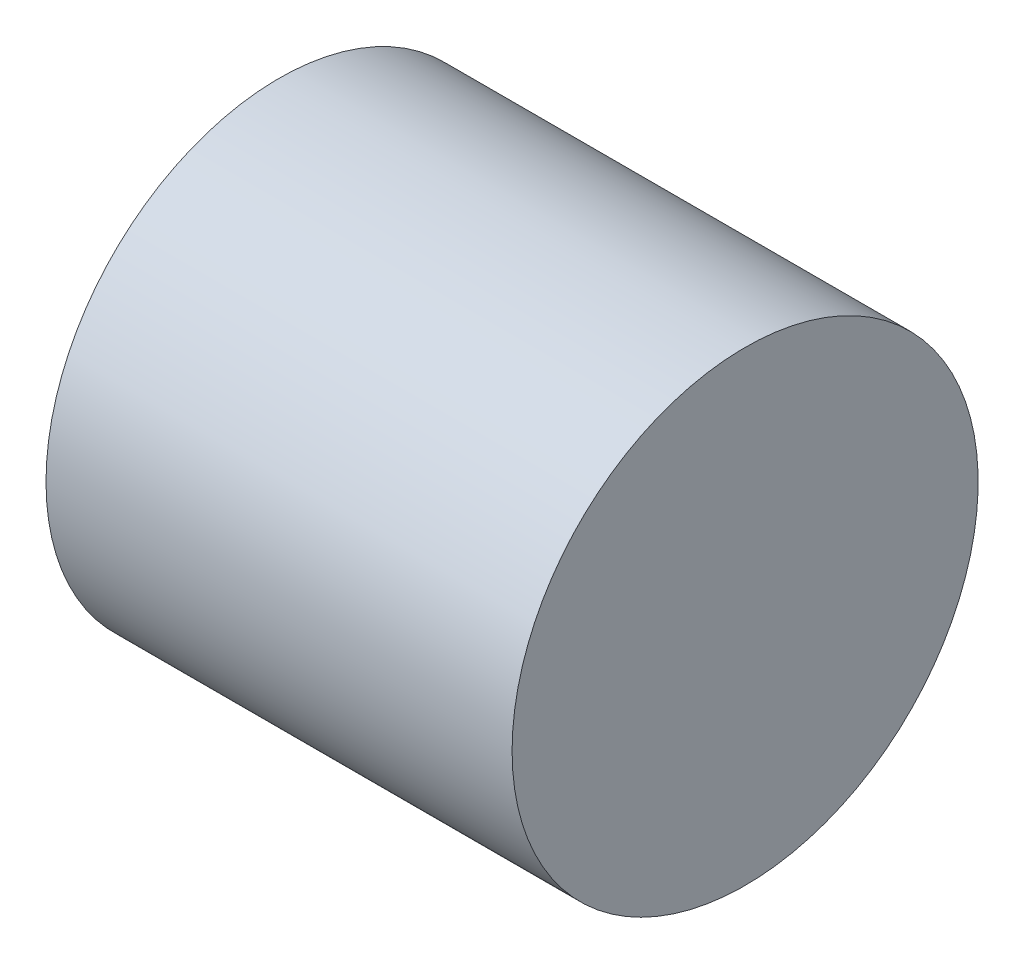
from build123d import *

# Parameters (mm, degrees)
SCHIZZO1_W = 40
SCHIZZO1_H = 20


with BuildPart() as part:
    # Schizzo1 → Rivoluzione1 (revolve)
    with BuildSketch(Plane.XY):
        with Locations((20, 10)):
            Rectangle(SCHIZZO1_W, SCHIZZO1_H)
    revolve(axis=Axis((0, 20, 0), (1, 0, 0)))


solid = part.part
